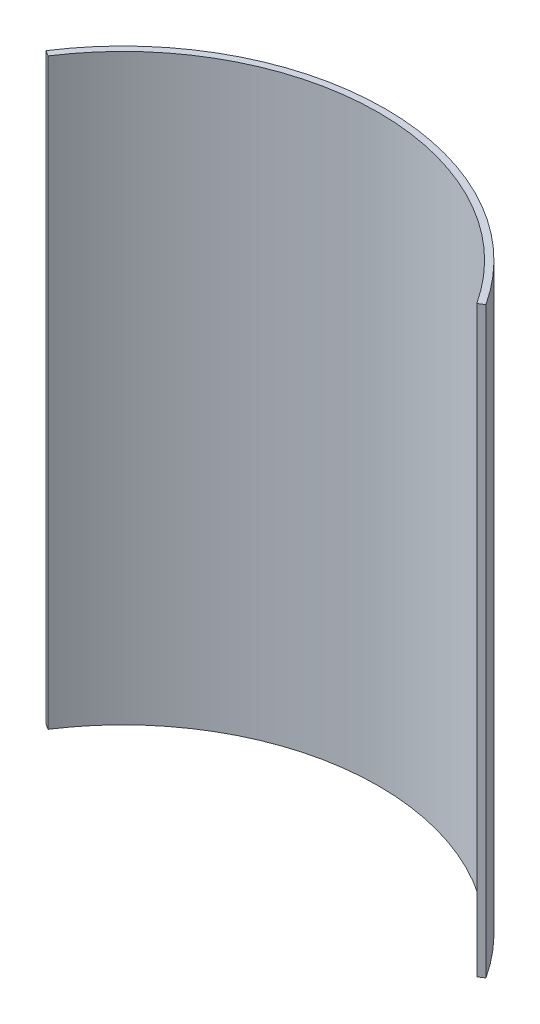
from build123d import *

# Parameters (mm, degrees)
BOSS_EXTRUDE1_DEPTH = 85.5


with BuildPart() as part:
    # Sketch1 → Boss-Extrude1 (new body)
    with BuildSketch(Plane(origin=(0, 0, 0), x_dir=(1, 0, 0), z_dir=(0, 1, 0))):
        with BuildLine():
            Line((-31.430031232, 20.454904955), (-32.243665164, 20.984424147))
            ThreePointArc((-32.243665164, 20.984424147), (0, 38.470768123), (32.243665164, 20.984424147))
            Line((32.243665164, 20.984424147), (31.430031232, 20.454904955))
            ThreePointArc((31.430031232, 20.454904955), (0, 37.5), (-31.430031232, 20.454904955))
        make_face()
    extrude(amount=-BOSS_EXTRUDE1_DEPTH)


solid = part.part
